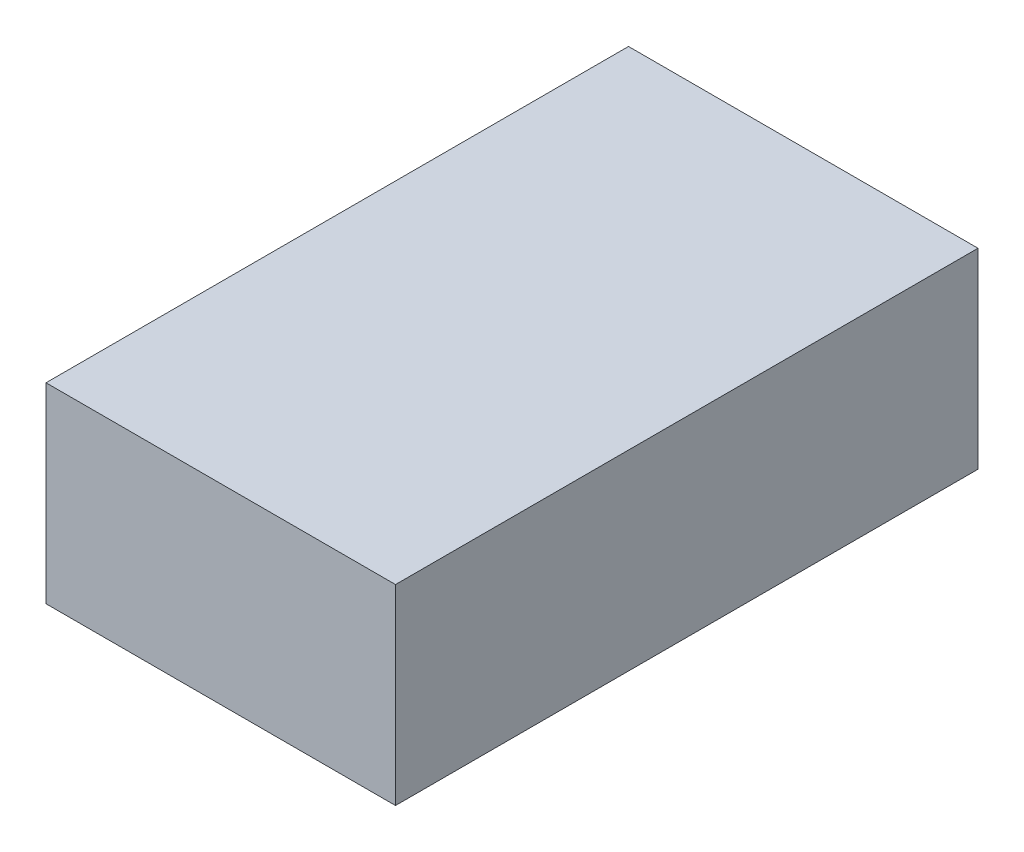
from build123d import *

# Parameters (mm, degrees)
SKETCH_1_W      = 21
SKETCH_1_H      = 35
EXTRUDE_1_DEPTH = 11.5


with BuildPart() as part:
    # 草图1 → 凸台-拉伸1 (new body)
    with BuildSketch(Plane(origin=(0, 0, 0), x_dir=(1, 0, 0), z_dir=(0, 1, 0))):
        Rectangle(SKETCH_1_W, SKETCH_1_H)
    extrude(amount=EXTRUDE_1_DEPTH)


solid = part.part
